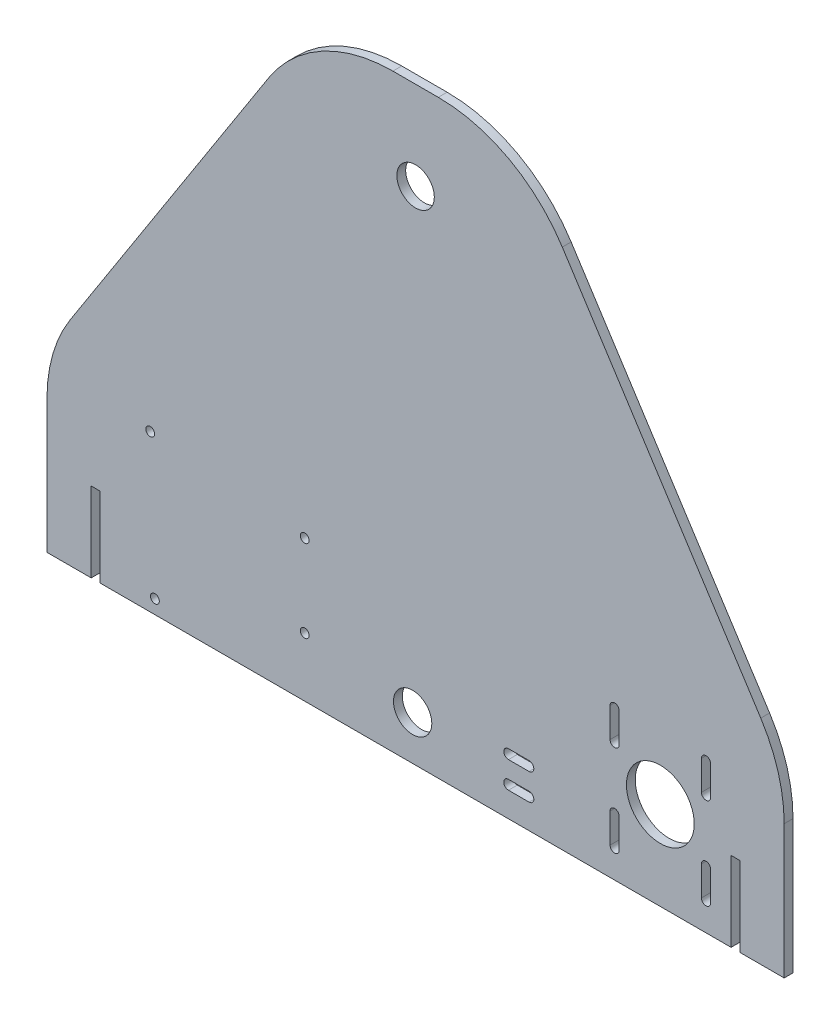
from build123d import *

# Parameters (mm, degrees)
CROQUIS1_R              = 6.35
SALIENTE_EXTRUIR1_DEPTH = 3
REDONDEO1_R             = 50
CROQUIS2_R              = 11.5
CORTAR_EXTRUIR1_DEPTH   = 10
CROQUIS6_W              = 3
CROQUIS6_H              = 27
CORTAR_EXTRUIR3_DEPTH   = 4
CROQUIS7_R              = 1.5
CORTAR_EXTRUIR4_DEPTH   = 4
CROQUIS8_R              = 6.5
CORTAR_EXTRUIR5_DEPTH   = 4
CORTAR_EXTRUIR6_DEPTH   = 4


with BuildPart() as part:
    # Croquis1 → Saliente-Extruir1 (new body)
    with BuildSketch(Plane.XY):
        Polygon((-35, 100), (-125, -40), (-125, -100), (125, -100), (125, -40), (35, 100), align=None)
        with Locations((0, 70)):
            Circle(CROQUIS1_R, mode=Mode.SUBTRACT)
    extrude(amount=SALIENTE_EXTRUIR1_DEPTH)

    # Redondeo1
    redondeo1_edges = [part.edges().sort_by_distance(p)[0] for p in [
        (125, -40, 1.5),
        (-125, -40, 1.5),
        (-35, 100, 1.5),
        (35, 100, 1.5),
    ]]
    fillet(redondeo1_edges, radius=REDONDEO1_R)

    # Croquis2 → Cortar-Extruir1 (cut)
    with BuildSketch(Plane.XY.offset(3)):
        with BuildLine():
            ThreePointArc((100, -54.5), (98.5, -53), (97, -54.5))
            Line((97, -54.5), (98.5, -54.5))
            Line((98.5, -54.5), (98.5, -56))
            ThreePointArc((98.5, -56), (99.560660172, -55.560660172), (100, -54.5))
        make_face()
        with BuildLine():
            Line((98.5, -54.5), (97, -54.5))
            ThreePointArc((97, -54.5), (97.439339828, -55.560660172), (98.5, -56))
            Line((98.5, -56), (98.5, -54.5))
        make_face()
        with BuildLine():
            Line((67.5, -56), (67.5, -54.5))
            Line((67.5, -54.5), (69, -54.5))
            ThreePointArc((69, -54.5), (66.439339828, -53.439339828), (67.5, -56))
        make_face()
        with BuildLine():
            Line((69, -54.5), (67.5, -54.5))
            Line((67.5, -54.5), (67.5, -56))
            ThreePointArc((67.5, -56), (68.560660172, -55.560660172), (69, -54.5))
        make_face()
        with Locations((83, -70)):
            Circle(CROQUIS2_R)
        with BuildLine():
            ThreePointArc((69, -85.5), (68.560660172, -84.439339828), (67.5, -84))
            Line((67.5, -84), (67.5, -85.5))
            Line((67.5, -85.5), (69, -85.5))
        make_face()
        with BuildLine():
            Line((67.5, -85.5), (67.5, -84))
            ThreePointArc((67.5, -84), (66.439339828, -86.560660172), (69, -85.5))
            Line((69, -85.5), (67.5, -85.5))
        make_face()
        with BuildLine():
            ThreePointArc((100, -85.5), (99.560660172, -84.439339828), (98.5, -84))
            Line((98.5, -84), (98.5, -85.5))
            Line((98.5, -85.5), (97, -85.5))
            ThreePointArc((97, -85.5), (98.5, -87), (100, -85.5))
        make_face()
        with BuildLine():
            Line((98.5, -85.5), (98.5, -84))
            ThreePointArc((98.5, -84), (97.439339828, -84.439339828), (97, -85.5))
            Line((97, -85.5), (98.5, -85.5))
        make_face()
    extrude(amount=-CORTAR_EXTRUIR1_DEPTH, mode=Mode.SUBTRACT)

    # Croquis6 → Cortar-Extruir3 (cut, through all)
    with BuildSketch(Plane(origin=(0, 0, 0), x_dir=(-1, 0, 0), z_dir=(0, 0, -1))):
        with Locations((-108.5, -86.5)):
            Rectangle(CROQUIS6_W, CROQUIS6_H)
        with Locations((108.5, -86.5)):
            Rectangle(CROQUIS6_W, CROQUIS6_H)
    extrude(amount=-CORTAR_EXTRUIR3_DEPTH, mode=Mode.SUBTRACT)

    # Croquis7 → Cortar-Extruir4 (cut, through all)
    with BuildSketch(Plane(origin=(0, 0, 0), x_dir=(-1, 0, 0), z_dir=(0, 0, -1))):
        with Locations((90, -47)):
            Circle(CROQUIS7_R)
        with Locations((37.6, -52.1)):
            Circle(CROQUIS7_R)
        with Locations((37.6, -80)):
            Circle(CROQUIS7_R)
        with Locations((88.4, -95.3)):
            Circle(CROQUIS7_R)
    extrude(amount=-CORTAR_EXTRUIR4_DEPTH, mode=Mode.SUBTRACT)

    # Croquis8 → Cortar-Extruir5 (cut, through all)
    with BuildSketch(Plane.XY.offset(3)):
        with Locations((-1, -85)):
            Circle(CROQUIS8_R)
        with BuildLine():
            Line((31.5, -88.4), (38.5, -88.4))
            ThreePointArc((38.5, -88.4), (40.1, -90), (38.5, -91.6))
            Line((38.5, -91.6), (31.5, -91.6))
            ThreePointArc((31.5, -91.6), (29.9, -90), (31.5, -88.4))
        make_face()
        with BuildLine():
            Line((31.5, -79.4), (38.5, -79.4))
            ThreePointArc((38.5, -79.4), (40.1, -81), (38.5, -82.6))
            Line((38.5, -82.6), (31.5, -82.6))
            ThreePointArc((31.5, -82.6), (29.9, -81), (31.5, -79.4))
        make_face()
    extrude(amount=-CORTAR_EXTRUIR5_DEPTH, mode=Mode.SUBTRACT)

    # Croquis9 → Cortar-Extruir6 (cut, through all)
    with BuildSketch(Plane(origin=(0, 0, 0), x_dir=(-1, 0, 0), z_dir=(0, 0, -1))):
        with BuildLine():
            Line((-96.95, -49.5), (-96.95, -59.5))
            ThreePointArc((-96.95, -59.5), (-98.5, -61.05), (-100.05, -59.5))
            Line((-100.05, -59.5), (-100.05, -49.5))
            ThreePointArc((-100.05, -49.5), (-98.5, -47.95), (-96.95, -49.5))
        make_face()
        with BuildLine():
            Line((-65.95, -49.5), (-65.95, -59.5))
            ThreePointArc((-65.95, -59.5), (-67.5, -61.05), (-69.05, -59.5))
            Line((-69.05, -59.5), (-69.05, -49.5))
            ThreePointArc((-69.05, -49.5), (-67.5, -47.95), (-65.95, -49.5))
        make_face()
        with BuildLine():
            Line((-69.05, -90.5), (-69.05, -80.5))
            ThreePointArc((-69.05, -80.5), (-67.5, -78.95), (-65.95, -80.5))
            Line((-65.95, -80.5), (-65.95, -90.5))
            ThreePointArc((-65.95, -90.5), (-67.5, -92.05), (-69.05, -90.5))
        make_face()
        with BuildLine():
            Line((-100.05, -90.5), (-100.05, -80.5))
            ThreePointArc((-100.05, -80.5), (-98.5, -78.95), (-96.95, -80.5))
            Line((-96.95, -80.5), (-96.95, -90.5))
            ThreePointArc((-96.95, -90.5), (-98.5, -92.05), (-100.05, -90.5))
        make_face()
    extrude(amount=-CORTAR_EXTRUIR6_DEPTH, mode=Mode.SUBTRACT)


solid = part.part
